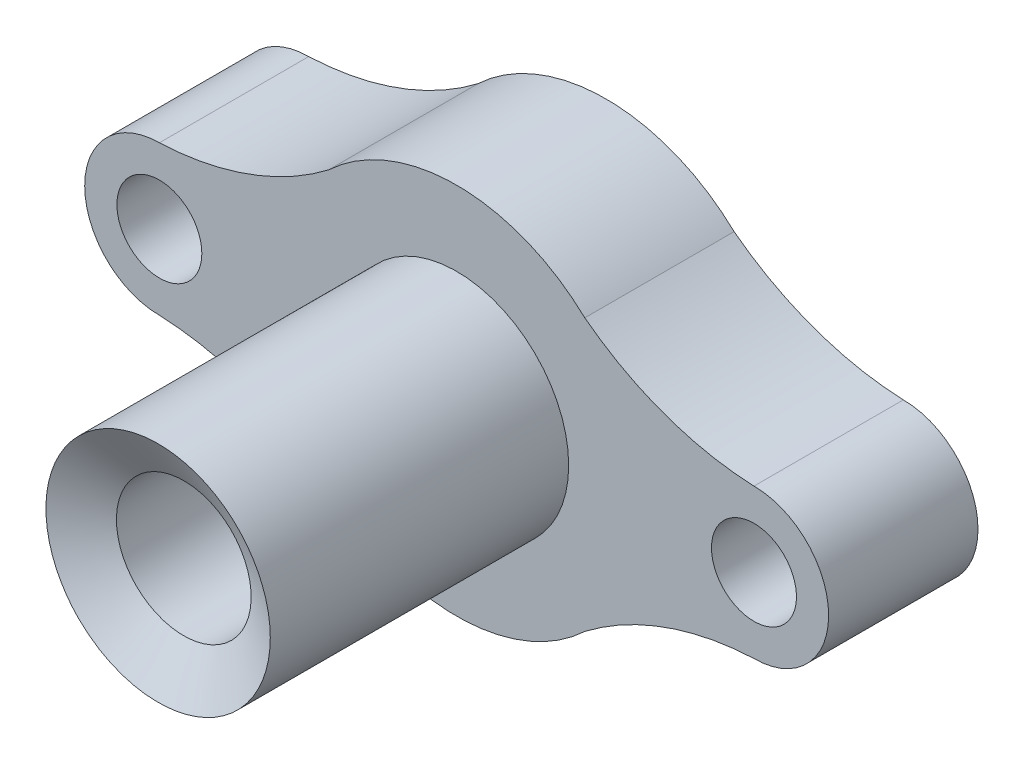
from build123d import *

# Parameters (mm, degrees)
SKETCH1_R           = 28.439830306
BOSS_EXTRUDE1_DEPTH = 100
SKETCH2_R           = 75
BOSS_EXTRUDE2_DEPTH = 200
SHELL2_T            = -30


with BuildPart() as part:
    # Sketch1 → Boss-Extrude1 (new body)
    with BuildSketch(Plane.XY):
        with BuildLine():
            ThreePointArc((-85.781855353, -90.920147889), (0, -125), (85.781855353, -90.920147889))
            ThreePointArc((85.781855353, -90.920147889), (139.265031386, -61.731062237), (199.054955441, -50))
            ThreePointArc((199.054955441, -50), (249.054955441, 0), (199.054955441, 50))
            ThreePointArc((199.054955441, 50), (139.265031386, 61.731062237), (85.781855353, 90.920147889))
            ThreePointArc((85.781855353, 90.920147889), (0, 125), (-85.781855353, 90.920147889))
            ThreePointArc((-85.781855353, 90.920147889), (-139.265031386, 61.731062237), (-199.054955441, 50))
            ThreePointArc((-199.054955441, 50), (-249.054955441, 0), (-199.054955441, -50))
            ThreePointArc((-199.054955441, -50), (-139.265031386, -61.731062237), (-85.781855353, -90.920147889))
        make_face()
        with Locations((-199.054955441, 0)):
            Circle(SKETCH1_R, mode=Mode.SUBTRACT)
        with Locations((199.054955441, 0)):
            Circle(SKETCH1_R, mode=Mode.SUBTRACT)
    extrude(amount=BOSS_EXTRUDE1_DEPTH)


with BuildPart() as body_2:
    # Sketch2 → Boss-Extrude2 (new body)
    with BuildSketch(Plane.XY.offset(100)):
        Circle(SKETCH2_R)
    extrude(amount=BOSS_EXTRUDE2_DEPTH)

    # Shell2
    shell2_openings = [body_2.faces().sort_by_distance(p)[0] for p in [
        (0, 0, 300),
    ]]
    offset(amount=SHELL2_T, openings=shell2_openings, kind=Kind.INTERSECTION)

    # Combine1: union part
    add(part.part)

    # Sketch4 → Cut-Revolve1 (revolve, cut)
    with BuildSketch(Plane(origin=(0, 0, 0), x_dir=(1, 0, 0), z_dir=(0, 1, 0))):
        Polygon((0.183143778, -256.900843522), (-75, -300), (0.183143778, -300), align=None)
    revolve(axis=Axis((0.183143778, 0, 300), (0, 0, -1)), mode=Mode.SUBTRACT)


solid = body_2.part
